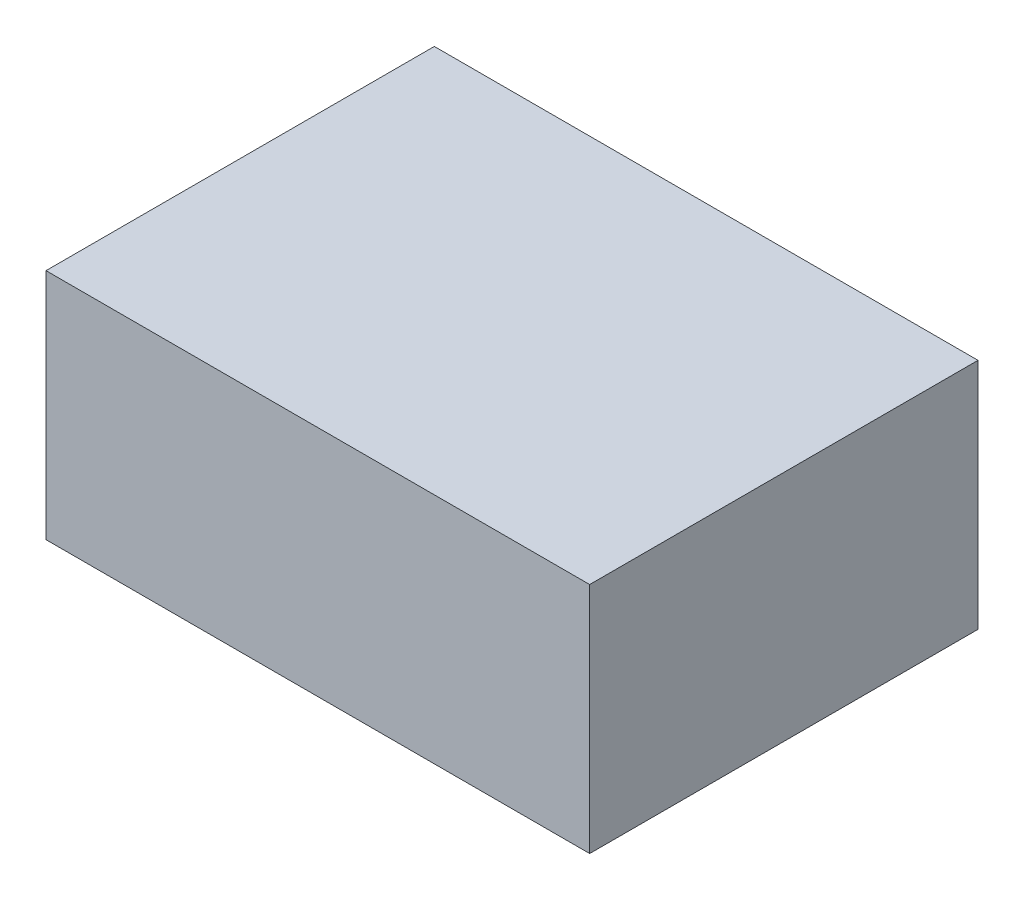
from build123d import *

# Parameters (mm, degrees)
SKETCH1_W           = 70
SKETCH1_H           = 50
BOSS_EXTRUDE1_DEPTH = 30


with BuildPart() as part:
    # Sketch1 → Boss-Extrude1 (new body)
    with BuildSketch(Plane(origin=(0, 0, 0), x_dir=(1, 0, 0), z_dir=(0, 1, 0))):
        with Locations((-17.378597763, -6.099792422)):
            Rectangle(SKETCH1_W, SKETCH1_H)
    extrude(amount=BOSS_EXTRUDE1_DEPTH)


solid = part.part
